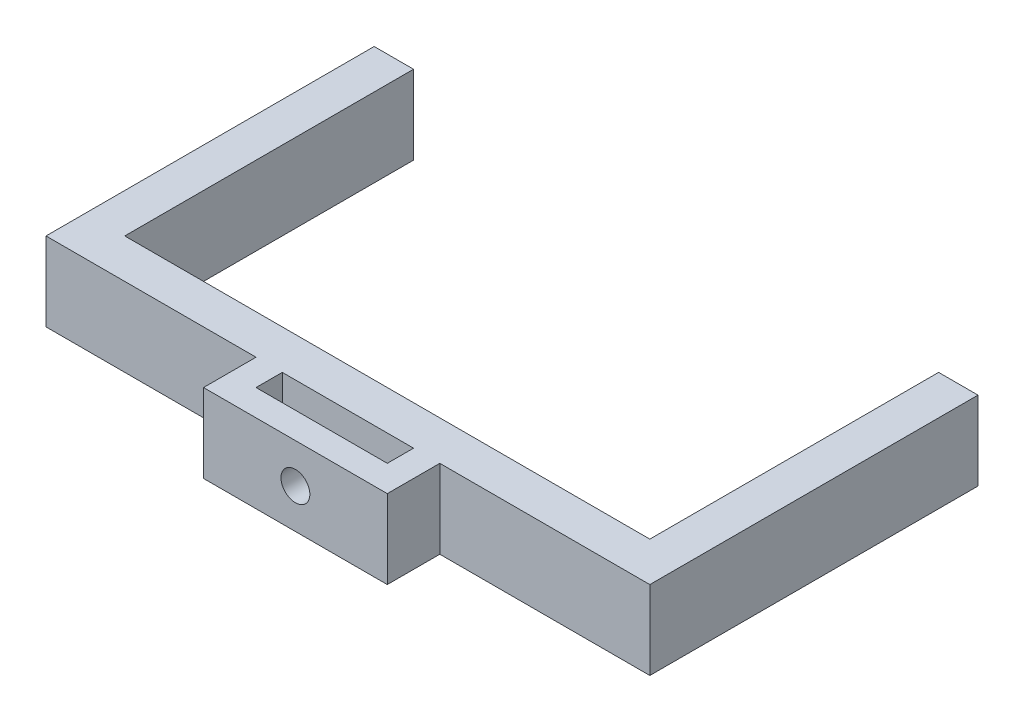
from build123d import *

# Parameters (mm, degrees)
BOSS_EXTRUDE1_DEPTH = 6
SKETCH2_R           = 1.1
CUT_EXTRUDE1_DEPTH  = 2


with BuildPart() as part:
    # Sketch1 → Boss-Extrude1 (new body)
    with BuildSketch(Plane(origin=(0, 0, 0), x_dir=(1, 0, 0), z_dir=(0, 1, 0))):
        Polygon((13, 0), (13, -4), (27, -4), (27, 0), (43, 0), (43, 25), (40, 25), (40, 3), (0, 3), (0, 25), (-3, 25), (-3, 0), align=None)
        Polygon((25, -2), (20, -2), (15, -2), (15, 0), (25, 0), align=None, mode=Mode.SUBTRACT)
    extrude(amount=BOSS_EXTRUDE1_DEPTH)

    # Sketch2 → Cut-Extrude1 (cut)
    with BuildSketch(Plane.XY.offset(4)):
        with Locations((20, 3)):
            Circle(SKETCH2_R)
    extrude(amount=-CUT_EXTRUDE1_DEPTH, mode=Mode.SUBTRACT)


solid = part.part
